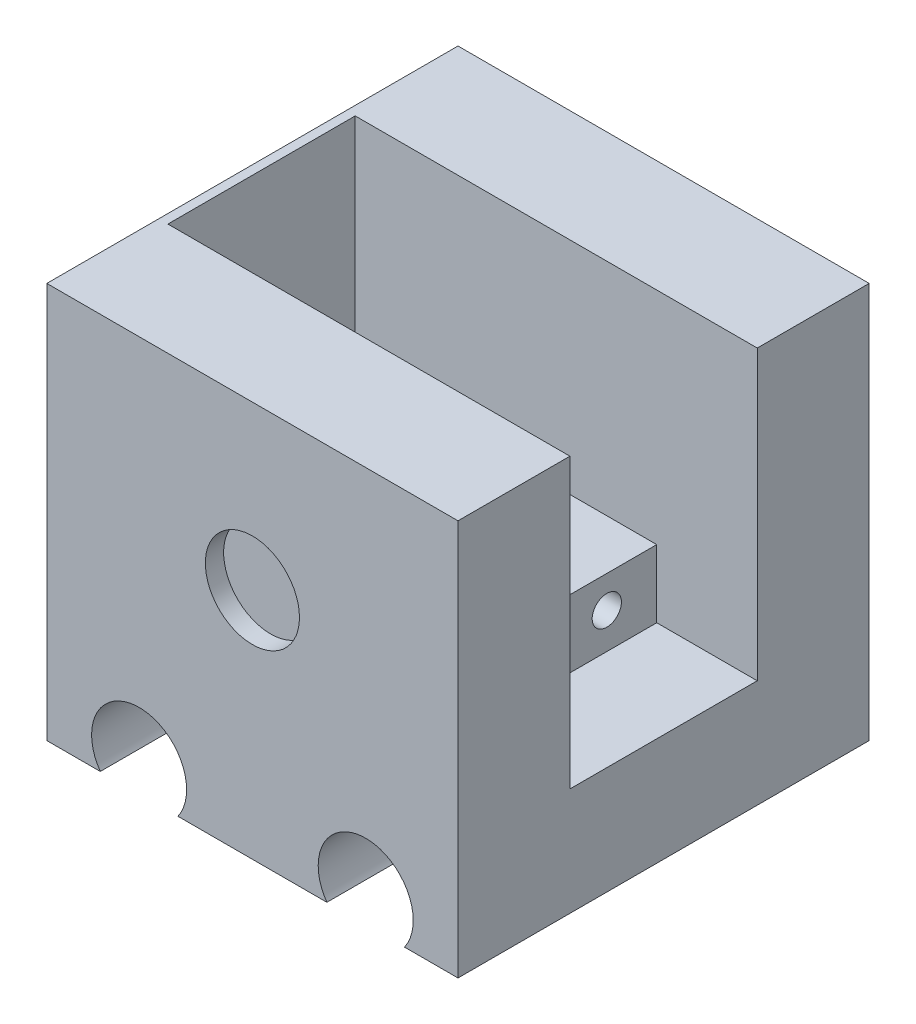
from build123d import *

# Parameters (mm, degrees)
SKETCH1_W                = 45
SKETCH1_H                = 50
BOSS_EXTRUDE1_DEPTH      = 45
SKETCH2_R                = 5.2
CUT_EXTRUDE1_DEPTH       = 45
SKETCH9_R                = 5.15
CUT_EXTRUDE6_DEPTH       = 2
SKETCH10_R               = 5.15
CUT_EXTRUDE7_DEPTH       = 2
SKETCH12_R               = 12.7
CUT_EXTRUDE8_DEPTH       = 46
SKETCH13_W               = 45
SKETCH13_H               = 6.66747138
CUT_EXTRUDE9_DEPTH       = 46
SKETCH16_R               = 13.25
SKETCH16_R_2             = 3.75
BOSS_EXTRUDE3_DEPTH      = 2
SKETCH20_R               = 12.7
BOSS_EXTRUDE4_DEPTH      = 45
SKETCH21_W               = 20.5
SKETCH21_H               = 40.5
CUT_EXTRUDE10_DEPTH      = 44
SKETCH22_R               = 2.15
BOSS_EXTRUDE5_DEPTH      = 44
SKETCH26_W               = 5.127085864
SKETCH26_H               = 8
CUT_EXTRUDE16_DEPTH      = 7
SKETCH28_R               = 2.15
BOSS_EXTRUDE6_DEPTH      = 44
SKETCH29_R               = 2.15
CUT_EXTRUDE18_DEPTH      = 10
SKETCH30_W               = 8
SKETCH30_H               = 7
CUT_EXTRUDE19_DEPTH      = 7
CUT_EXTRUDE19_DEPTH_BACK = 7
SKETCH31_W               = 20.5
SKETCH31_H               = 7.407828578
CUT_EXTRUDE20_DEPTH      = 11
SKETCH32_W               = 9
SKETCH32_H               = 5.046358254
CUT_EXTRUDE21_DEPTH      = 14
SKETCH33_W               = 8.088030226
SKETCH33_H               = 9
CUT_EXTRUDE22_DEPTH      = 7
SKETCH34_R               = 1.6
CUT_EXTRUDE23_DEPTH      = 10
SKETCH35_W               = 5
SKETCH35_H               = 9
CUT_EXTRUDE24_DEPTH      = 7


with BuildPart() as part:
    # Sketch1 → Boss-Extrude1 (new body)
    with BuildSketch(Plane.XY):
        with Locations((8.236607143, -2.901785714)):
            Rectangle(SKETCH1_W, SKETCH1_H)
    extrude(amount=BOSS_EXTRUDE1_DEPTH)

    # Sketch2 → Cut-Extrude1 (cut)
    with BuildSketch(Plane.XY.offset(45)):
        with Locations((-4.163392857, -24.901785714)):
            Circle(SKETCH2_R)
        with Locations((20.636607143, -24.901785714)):
            Circle(SKETCH2_R)
    extrude(amount=-CUT_EXTRUDE1_DEPTH, mode=Mode.SUBTRACT)

    # Sketch9 → Cut-Extrude6 (cut)
    with BuildSketch(Plane.XY.offset(45)):
        with Locations((8.236607143, -2.401785714)):
            Circle(SKETCH9_R)
    extrude(amount=-CUT_EXTRUDE6_DEPTH, mode=Mode.SUBTRACT)

    # Sketch10 → Cut-Extrude7 (cut)
    with BuildSketch(Plane(origin=(0, 0, 0), x_dir=(-1, 0, 0), z_dir=(0, 0, -1))):
        with Locations((-8.236607143, -2.401785714)):
            Circle(SKETCH10_R)
    extrude(amount=-CUT_EXTRUDE7_DEPTH, mode=Mode.SUBTRACT)

    # Sketch12 → Cut-Extrude8 (cut)
    with BuildSketch(Plane.ZY.offset(14.263392857)):
        with Locations((22.5, 0)):
            Circle(SKETCH12_R)
    extrude(amount=-CUT_EXTRUDE8_DEPTH, mode=Mode.SUBTRACT)

    # Sketch13 → Cut-Extrude9 (cut)
    with BuildSketch(Plane.ZY.offset(14.263392857)):
        with Locations((22.5, 18.764478596)):
            Rectangle(SKETCH13_W, SKETCH13_H)
    extrude(amount=-CUT_EXTRUDE9_DEPTH, mode=Mode.SUBTRACT)

    # Sketch16 → Boss-Extrude3 (add)
    with BuildSketch(Plane(origin=(30.736607143, 0, 0), x_dir=(0, 0, -1), z_dir=(1, 0, 0))):
        with Locations((-22.5, 0)):
            Circle(SKETCH16_R)
        with Locations((-22.5, 0)):
            Circle(SKETCH16_R_2, mode=Mode.SUBTRACT)
    extrude(amount=-BOSS_EXTRUDE3_DEPTH)

    # Sketch20 → Boss-Extrude4 (add)
    with BuildSketch(Plane.ZY.offset(14.263392857)):
        with Locations((22.5, 0)):
            Circle(SKETCH20_R)
    extrude(amount=-BOSS_EXTRUDE4_DEPTH)

    # Sketch21 → Cut-Extrude10 (cut)
    with BuildSketch(Plane(origin=(30.736607143, 0, 0), x_dir=(0, 0, -1), z_dir=(1, 0, 0))):
        with Locations((-22.5, 3.75)):
            Rectangle(SKETCH21_W, SKETCH21_H)
    extrude(amount=-CUT_EXTRUDE10_DEPTH, mode=Mode.SUBTRACT)

    # Sketch22 → Boss-Extrude5 (add)
    with BuildSketch(Plane(origin=(30.736607143, 0, 0), x_dir=(0, 0, -1), z_dir=(1, 0, 0))):
        Polygon((-32.5, -8.699027625), (-12.5, -8.699027625), (-12.25, -8.699027625), (-12.25, -16.5), (-32.75, -16.5), (-32.75, -8.699027625), align=None)
        with Locations((-27.215250341, -10.949027625)):
            Circle(SKETCH22_R, mode=Mode.SUBTRACT)
        with Locations((-17.715250341, -10.949027625)):
            Circle(SKETCH22_R, mode=Mode.SUBTRACT)
    extrude(amount=-BOSS_EXTRUDE5_DEPTH)

    # Sketch26 → Cut-Extrude16 (cut)
    with BuildSketch(Plane(origin=(0, -8.699027625, 0), x_dir=(1, 0, 0), z_dir=(0, 1, 0))):
        with Locations((-10.699849925, -22.5)):
            Rectangle(SKETCH26_W, SKETCH26_H)
    extrude(amount=-CUT_EXTRUDE16_DEPTH, mode=Mode.SUBTRACT)

    # Sketch28 → Boss-Extrude6 (add)
    with BuildSketch(Plane(origin=(30.736607143, 0, 0), x_dir=(0, 0, -1), z_dir=(1, 0, 0))):
        with Locations((-27.215250341, -10.949027625)):
            Circle(SKETCH28_R)
        with Locations((-17.715250341, -10.949027625)):
            Circle(SKETCH28_R)
    extrude(amount=-BOSS_EXTRUDE6_DEPTH)

    # Sketch29 → Cut-Extrude18 (cut)
    with BuildSketch(Plane(origin=(30.736607143, 0, 0), x_dir=(0, 0, -1), z_dir=(1, 0, 0))):
        with Locations((-27.215250341, -12.199027625)):
            Circle(SKETCH29_R)
        with Locations((-17.715250341, -12.199027625)):
            Circle(SKETCH29_R)
    extrude(amount=-CUT_EXTRUDE18_DEPTH, mode=Mode.SUBTRACT)

    # Sketch30 → Cut-Extrude19 (cut, two sides)
    with BuildSketch(Plane(origin=(-13.263392857, 0, 0), x_dir=(0, 0, -1), z_dir=(1, 0, 0))) as cut_extrude19_sk:
        with Locations((-22.5, -12.199027625)):
            Rectangle(SKETCH30_W, SKETCH30_H)
    extrude(amount=CUT_EXTRUDE19_DEPTH, mode=Mode.SUBTRACT)
    extrude(cut_extrude19_sk.sketch, amount=-CUT_EXTRUDE19_DEPTH_BACK, mode=Mode.SUBTRACT)

    # Sketch31 → Cut-Extrude20 (cut)
    with BuildSketch(Plane(origin=(30.736607143, 0, 0), x_dir=(0, 0, -1), z_dir=(1, 0, 0))):
        with Locations((-22.5, -12.402941914)):
            Rectangle(SKETCH31_W, SKETCH31_H)
    extrude(amount=-CUT_EXTRUDE20_DEPTH, mode=Mode.SUBTRACT)

    # Sketch32 → Cut-Extrude21 (cut)
    with BuildSketch(Plane(origin=(-13.263392857, 0, 0), x_dir=(0, 0, -1), z_dir=(1, 0, 0))):
        with Locations((-22.5, -6.175848498)):
            Rectangle(SKETCH32_W, SKETCH32_H)
    extrude(amount=-CUT_EXTRUDE21_DEPTH, mode=Mode.SUBTRACT)

    # Sketch33 → Cut-Extrude22 (cut)
    with BuildSketch(Plane(origin=(0, -8.699027625, 0), x_dir=(1, 0, 0), z_dir=(0, 1, 0))):
        with Locations((-10.219377744, -22.5)):
            Rectangle(SKETCH33_W, SKETCH33_H)
    extrude(amount=-CUT_EXTRUDE22_DEPTH, mode=Mode.SUBTRACT)

    # Sketch34 → Cut-Extrude23 (cut)
    with BuildSketch(Plane(origin=(19.736607143, 0, 0), x_dir=(0, 0, -1), z_dir=(1, 0, 0))):
        with Locations((-27.215250341, -12.199027625)):
            Circle(SKETCH34_R)
        with Locations((-17.715250341, -12.199027625)):
            Circle(SKETCH34_R)
    extrude(amount=-CUT_EXTRUDE23_DEPTH, mode=Mode.SUBTRACT)

    # Sketch35 → Cut-Extrude24 (cut)
    with BuildSketch(Plane(origin=(0, -8.699027625, 0), x_dir=(1, 0, 0), z_dir=(0, 1, 0))):
        with Locations((-3.675362631, -22.5)):
            Rectangle(SKETCH35_W, SKETCH35_H)
    extrude(amount=-CUT_EXTRUDE24_DEPTH, mode=Mode.SUBTRACT)


solid = part.part
